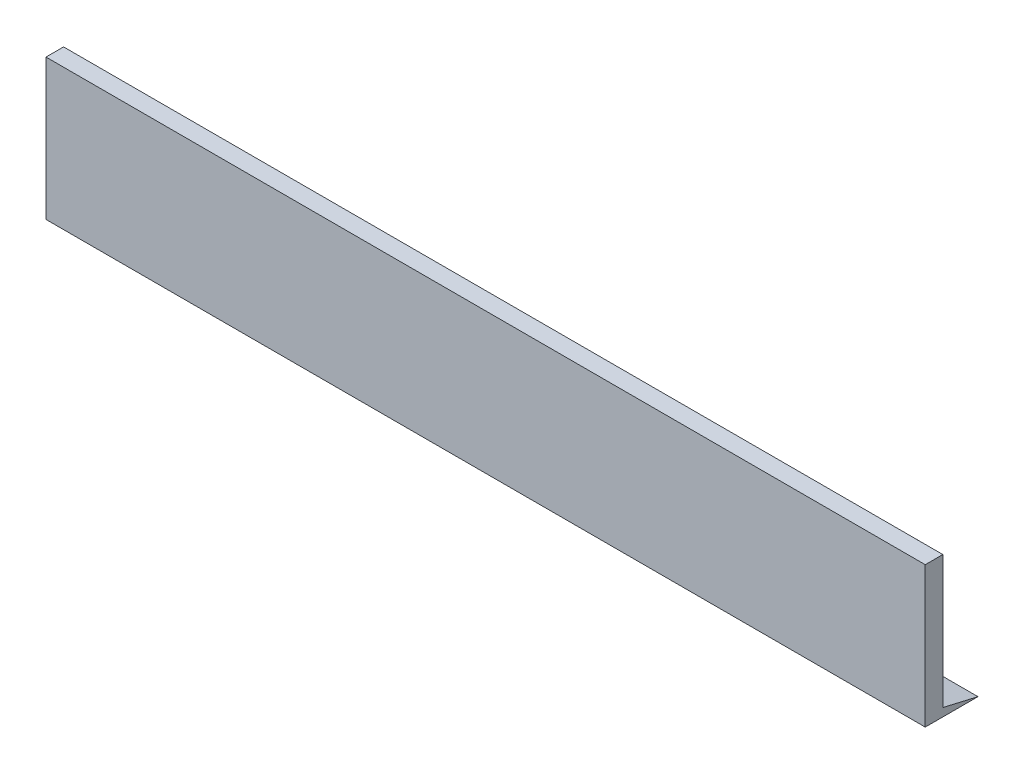
from build123d import *

# Parameters (mm, degrees)
ESQUISSE1_W        = 250
ESQUISSE1_H        = 40
BOSS_EXTRU_1_DEPTH = 5
BOSS_EXTRU_2_DEPTH = 250


with BuildPart() as part:
    # Esquisse1 → Boss.-Extru.1 (new body)
    with BuildSketch(Plane.XY):
        with Locations((125, 20)):
            Rectangle(ESQUISSE1_W, ESQUISSE1_H)
    extrude(amount=BOSS_EXTRU_1_DEPTH)

    # Esquisse2 → Boss.-Extru.2 (add)
    with BuildSketch(Plane.ZY):
        Polygon((0, 0), (-10, 0), (0, 2.320632566), align=None)
    extrude(amount=-BOSS_EXTRU_2_DEPTH)


solid = part.part
